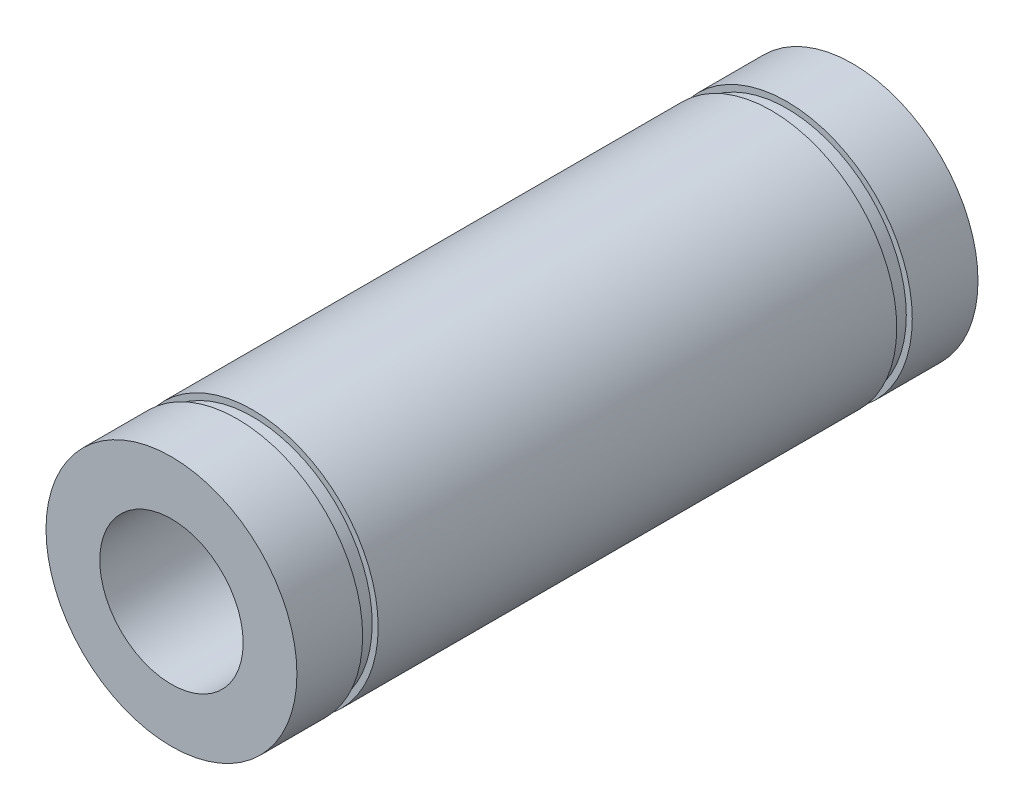
from build123d import *


with BuildPart() as part:
    # Sketch1 → Revolve1 (revolve)
    with BuildSketch(Plane(origin=(0, 0, 0), x_dir=(1, 0, 0), z_dir=(0, 1, 0))):
        Polygon((10.5, 22), (6, 22), (6, -35), (10.5, -35), (10.5, -29.5), (10, -29.5), (10, -28.2), (10.5, -28.2), (10.5, 15.2), (10, 15.2), (10, 16.5), (10.5, 16.5), align=None)
    revolve(axis=Axis((0, 0, 0), (0, 0, 1)))


solid = part.part
